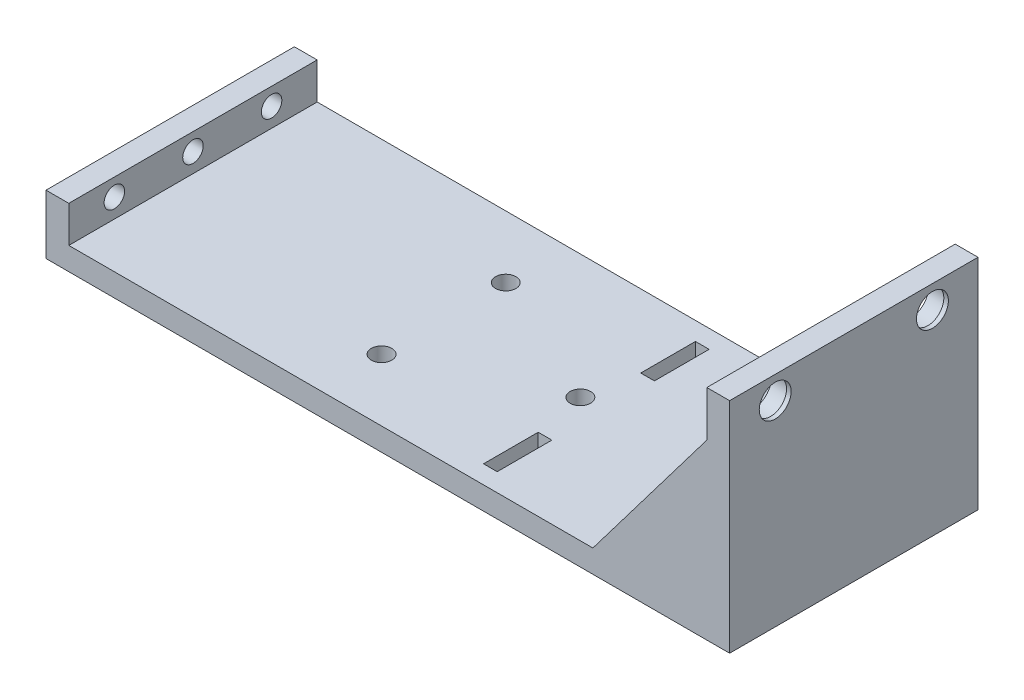
from build123d import *

# Parameters (mm, degrees)
SKETCH1_W                 = 150
SKETCH1_H                 = 54.5
BOSS_EXTRUDE1_DEPTH       = 5
SKETCH2_W                 = 5
SKETCH2_H                 = 54.5
BOSS_EXTRUDE2_DEPTH       = 8
F_8_CLEARANCE_HOLE1_D     = 4.4958
F_8_CLEARANCE_HOLE1_DEPTH = 17
F_8_CLEARANCE_HOLE1_TIP   = 1.350674586
SKETCH7_W                 = 5
SKETCH7_H                 = 54.5
BOSS_EXTRUDE3_DEPTH       = 43
SKETCH8_R                 = 4.25
CUT_EXTRUDE1_DEPTH        = 4
RIB1_REACH                = 120.085
SKETCH10_WALL_W           = 279.571445908
SKETCH10_WALL_H           = 10
RIB3_REACH                = 120.085
SKETCH12_WALL_W           = 279.571445908
SKETCH12_WALL_H           = 10
SKETCH13_W                = 8
SKETCH13_H                = 2
BOSS_EXTRUDE4_DEPTH       = 5
SKETCH14_R                = 2
CUT_EXTRUDE2_DEPTH        = 2
SKETCH15_R                = 3.5
CUT_EXTRUDE3_DEPTH        = 1
SKETCH16_W                = 3
SKETCH16_H                = 12
CUT_EXTRUDE4_DEPTH        = 5
F_8_CLEARANCE_HOLE2_D     = 4.4958
F_8_CLEARANCE_HOLE2_DEPTH = 17
F_8_CLEARANCE_HOLE2_TIP   = 1.350674586


with BuildPart() as part:
    # Sketch1 → Boss-Extrude1 (new body)
    with BuildSketch(Plane(origin=(0, 0, 0), x_dir=(1, 0, 0), z_dir=(0, 1, 0))):
        with Locations((-18.112463826, -1.689393939)):
            Rectangle(SKETCH1_W, SKETCH1_H)
    extrude(amount=BOSS_EXTRUDE1_DEPTH)

    # Sketch2 → Boss-Extrude2 (add)
    with BuildSketch(Plane(origin=(0, 5, 0), x_dir=(1, 0, 0), z_dir=(0, 1, 0))):
        with Locations((-90.612463826, -1.689393939)):
            Rectangle(SKETCH2_W, SKETCH2_H)
    extrude(amount=BOSS_EXTRUDE2_DEPTH)

    # #8 Clearance Hole1
    with Locations(Plane(origin=(-93.112463826, 9.2, -15.560606061), x_dir=(0, 0, -1), z_dir=(-1, 0, 0))):
        with Locations((0, 0), (-17.25, 0), (-34.5, 0)):
            Hole(F_8_CLEARANCE_HOLE1_D / 2, depth=F_8_CLEARANCE_HOLE1_DEPTH)
            with Locations((0, 0, -(F_8_CLEARANCE_HOLE1_DEPTH + F_8_CLEARANCE_HOLE1_TIP / 2))):  # 118° drill point
                Cone(0, F_8_CLEARANCE_HOLE1_D / 2, F_8_CLEARANCE_HOLE1_TIP, mode=Mode.SUBTRACT)

    # Sketch7 → Boss-Extrude3 (add)
    with BuildSketch(Plane(origin=(0, 5, 0), x_dir=(1, 0, 0), z_dir=(0, 1, 0))):
        with Locations((54.387536174, -1.689393939)):
            Rectangle(SKETCH7_W, SKETCH7_H)
    extrude(amount=BOSS_EXTRUDE3_DEPTH)

    # Sketch8 → Cut-Extrude1 (cut)
    with BuildSketch(Plane.ZY.offset(-51.887536174)):
        with Locations((-15.560606061, 43)):
            Circle(SKETCH8_R)
        with Locations((18.939393939, 43)):
            Circle(SKETCH8_R)
    extrude(amount=-CUT_EXTRUDE1_DEPTH, mode=Mode.SUBTRACT)

    # Sketch10 wall → Rib1 (add, up to next)
    with BuildSketch(Plane(origin=(39.387536174, 21.5, -25.560606061), x_dir=(-0.603857687995, -0.797092148154, 0), z_dir=(-0.797092148154, 0.603857687995, 0)), mode=Mode.PRIVATE) as rib1_sk1:
        with Locations((0, 5)):
            Rectangle(SKETCH10_WALL_W, SKETCH10_WALL_H)
    rib1_tool1 = extrude(rib1_sk1.sketch, amount=-RIB1_REACH, mode=Mode.PRIVATE) - part.part
    add(rib1_tool1.solids().sort_by_distance((39.387536174, 21.5, -25.560606061))[0])

    # Sketch12 wall → Rib3 (add, up to next)
    with BuildSketch(Plane(origin=(39.387536174, 21.5, 28.939393939), x_dir=(-0.603857687995, -0.797092148154, 0), z_dir=(0.797092148154, -0.603857687995, 0)), mode=Mode.PRIVATE) as rib3_sk1:
        with Locations((0, 5)):
            Rectangle(SKETCH12_WALL_W, SKETCH12_WALL_H)
    rib3_tool1 = extrude(rib3_sk1.sketch, amount=RIB3_REACH, mode=Mode.PRIVATE) - part.part
    add(rib3_tool1.solids().sort_by_distance((39.387536174, 21.5, 28.939393939))[0])

    # Sketch13 → Boss-Extrude4 (add)
    with BuildSketch(Plane.ZY.offset(-51.887536174)):
        with Locations((1.689393939, 37)):
            Rectangle(SKETCH13_W, SKETCH13_H)
    extrude(amount=BOSS_EXTRUDE4_DEPTH)

    # Sketch14 → Cut-Extrude2 (cut)
    with BuildSketch(Plane(origin=(0, 38, 0), x_dir=(1, 0, 0), z_dir=(0, 1, 0))):
        with Locations(Location((49.387536174, -1.689393939, 0), (0, 0, 270))):
            Circle(SKETCH14_R)
    extrude(amount=-CUT_EXTRUDE2_DEPTH, mode=Mode.SUBTRACT)

    # Sketch15 → Cut-Extrude3 (cut)
    with BuildSketch(Plane.ZY.offset(-55.887536174)):
        with Locations((-15.560606061, 43)):
            Circle(SKETCH15_R)
        with Locations((18.939393939, 43)):
            Circle(SKETCH15_R)
    extrude(amount=-CUT_EXTRUDE3_DEPTH, mode=Mode.SUBTRACT)

    # Sketch16 → Cut-Extrude4 (cut)
    with BuildSketch(Plane(origin=(0, 5, 0), x_dir=(1, 0, 0), z_dir=(0, 1, 0))):
        with Locations((0.387536174, 15.560606061)):
            Rectangle(SKETCH16_W, SKETCH16_H)
        with Locations((0.387536174, -18.939393939)):
            Rectangle(SKETCH16_W, SKETCH16_H)
    extrude(amount=-CUT_EXTRUDE4_DEPTH, mode=Mode.SUBTRACT)

    # #8 Clearance Hole2
    with Locations(Plane(origin=(-3.112463826, 5, 1.689393939), x_dir=(0, 0, 1), z_dir=(0, 1, 0))):
        with Locations((0, 0), (13.625, -30), (-13.625, -30)):
            Hole(F_8_CLEARANCE_HOLE2_D / 2, depth=F_8_CLEARANCE_HOLE2_DEPTH)
            with Locations((0, 0, -(F_8_CLEARANCE_HOLE2_DEPTH + F_8_CLEARANCE_HOLE2_TIP / 2))):  # 118° drill point
                Cone(0, F_8_CLEARANCE_HOLE2_D / 2, F_8_CLEARANCE_HOLE2_TIP, mode=Mode.SUBTRACT)


solid = part.part
